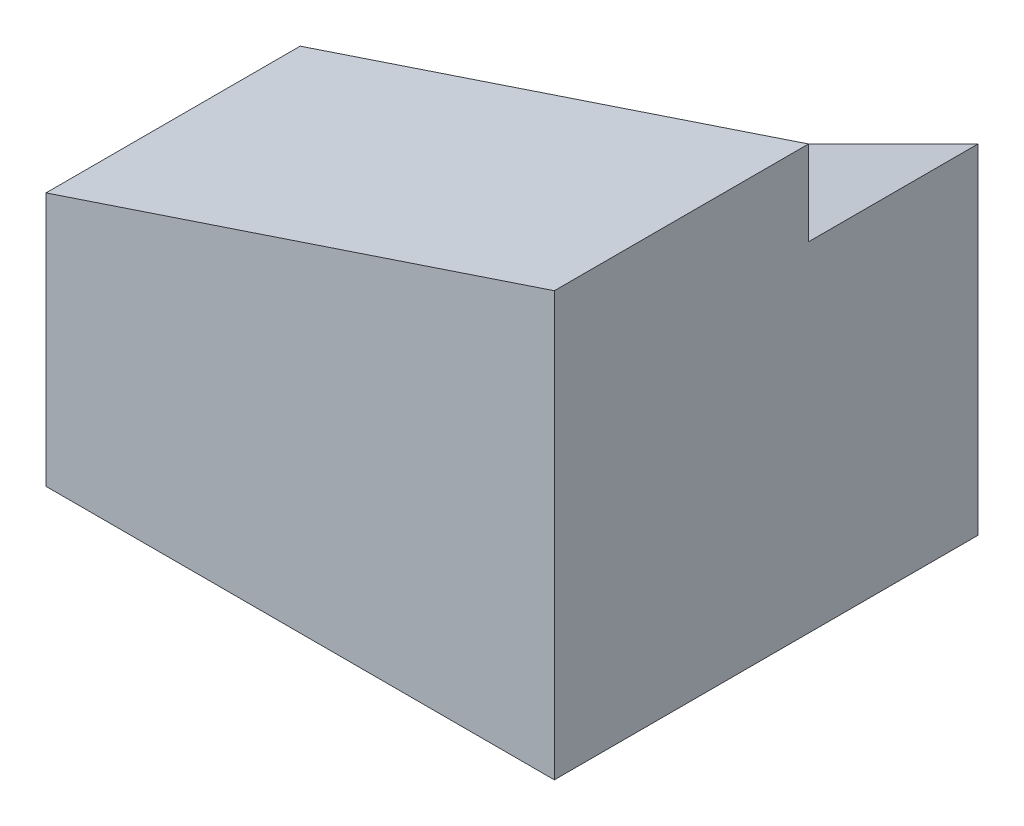
from build123d import *

# Parameters (mm, degrees)
SKETCH1_W           = 30
SKETCH1_H           = 25
BOSS_EXTRUDE1_DEPTH = 25
CUT_EXTRUDE1_DEPTH  = 26
CUT_EXTRUDE2_DEPTH  = 10


with BuildPart() as part:
    # Sketch1 → Boss-Extrude1 (new body)
    with BuildSketch(Plane.XY):
        Rectangle(SKETCH1_W, SKETCH1_H)
    extrude(amount=BOSS_EXTRUDE1_DEPTH)

    # Sketch3 → Cut-Extrude1 (cut, through all)
    with BuildSketch(Plane.XY.offset(25)):
        Polygon((15, 12.5), (-15, 2.5), (-15, 12.5), align=None)
    extrude(amount=-CUT_EXTRUDE1_DEPTH, mode=Mode.SUBTRACT)

    # Sketch4 → Cut-Extrude2 (cut)
    with BuildSketch(Plane(origin=(0, 0, 0), x_dir=(-1, 0, 0), z_dir=(0, 0, -1))):
        Polygon((-15, 12.5), (-15, 7.5), (15, -7.5), (15, 2.5), align=None)
    extrude(amount=-CUT_EXTRUDE2_DEPTH, mode=Mode.SUBTRACT)


solid = part.part
